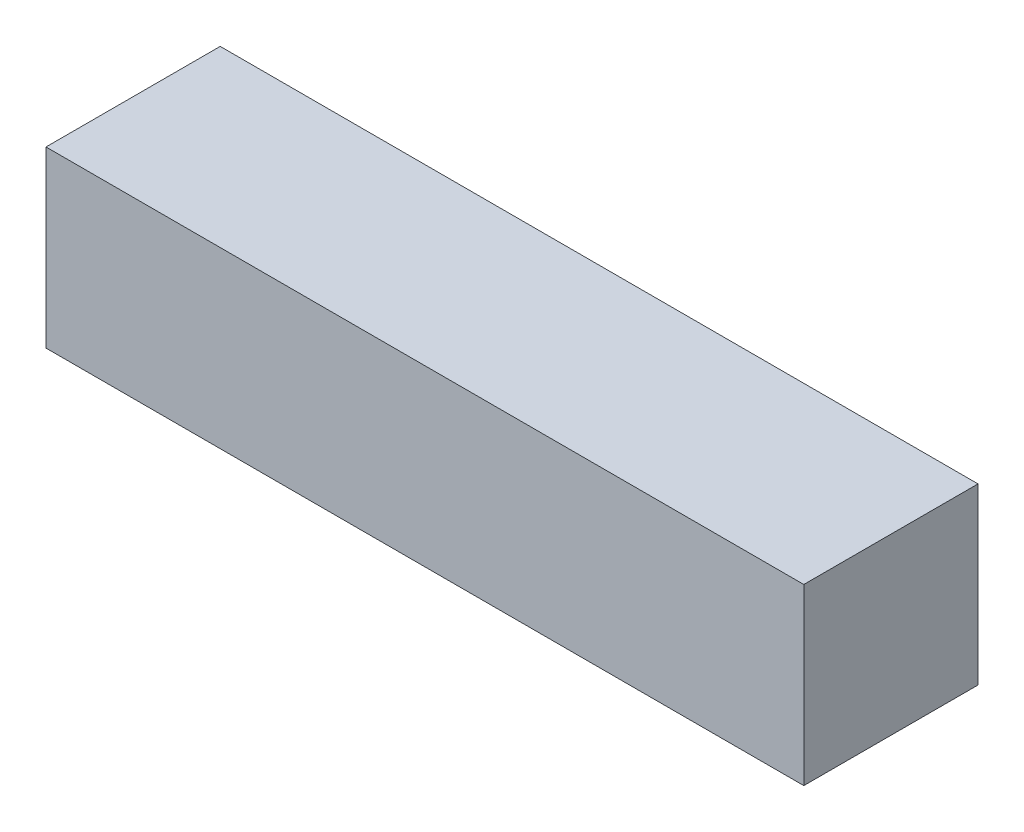
from build123d import *

# Parameters (mm, degrees)
SKETCH_1_W      = 87
SKETCH_1_H      = 20
EXTRUDE_1_DEPTH = 20


with BuildPart() as part:
    # 草圖1 → 填料-伸長1 (new body)
    with BuildSketch(Plane.XY):
        Rectangle(SKETCH_1_W, SKETCH_1_H)
    extrude(amount=EXTRUDE_1_DEPTH)


solid = part.part
